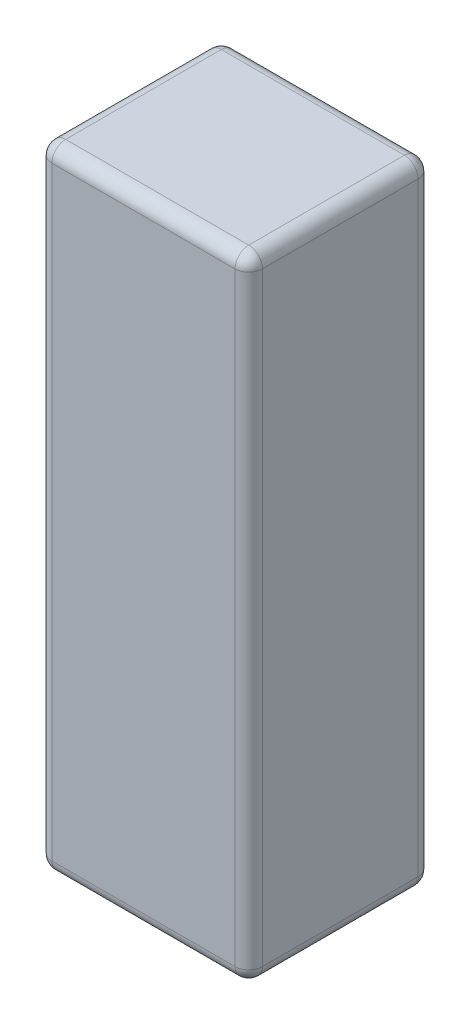
from build123d import *

# Parameters (mm, degrees)
SKETCH1_W           = 46
SKETCH1_H           = 40
BOSS_EXTRUDE1_DEPTH = 138
FILLET1_R           = 3


with BuildPart() as part:
    # Sketch1 → Boss-Extrude1 (new body)
    with BuildSketch(Plane(origin=(0, 0, 0), x_dir=(1, 0, 0), z_dir=(0, 1, 0))):
        Rectangle(SKETCH1_W, SKETCH1_H)
    extrude(amount=BOSS_EXTRUDE1_DEPTH)

    # Fillet1
    fillet1_edges = [part.edges().sort_by_distance(p)[0] for p in [
        (-23, 138, 0),
        (0, 138, 20),
        (23, 138, 0),
        (0, 0, 20),
        (-23, 0, 0),
        (0, 0, -20),
        (23, 0, 0),
        (0, 138, -20),
        (23, 69, 20),
        (-23, 69, 20),
        (-23, 69, -20),
        (23, 69, -20),
    ]]
    fillet(fillet1_edges, radius=FILLET1_R)


solid = part.part
